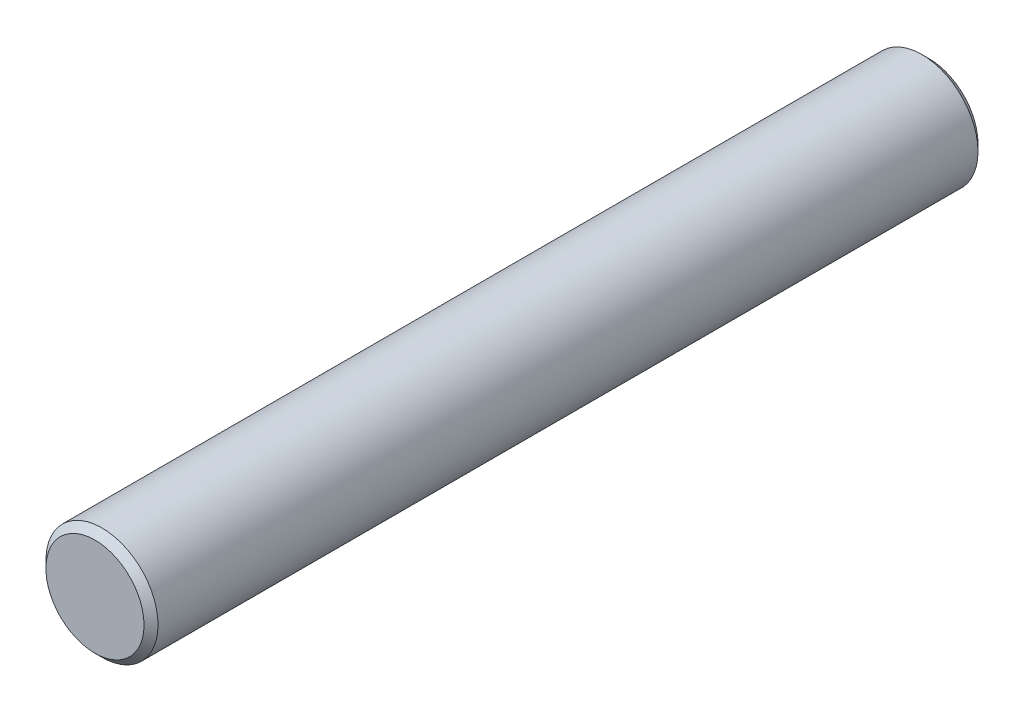
from build123d import *

# Parameters (mm, degrees)
SKETCH2_R           = 8
BOSS_EXTRUDE1_DEPTH = 59.5
CHAMFER1_SIZE       = 1


with BuildPart() as part:
    # Sketch2 → Boss-Extrude1 (new body, symmetric)
    with BuildSketch(Plane.XY):
        Circle(SKETCH2_R)
    extrude(amount=BOSS_EXTRUDE1_DEPTH, both=True)

    # Chamfer1
    chamfer1_edges = [part.edges().sort_by_distance(p)[0] for p in [
        (-8, 0, -59.5),
        (-8, 0, 59.5),
    ]]
    chamfer(chamfer1_edges, length=CHAMFER1_SIZE)


solid = part.part
